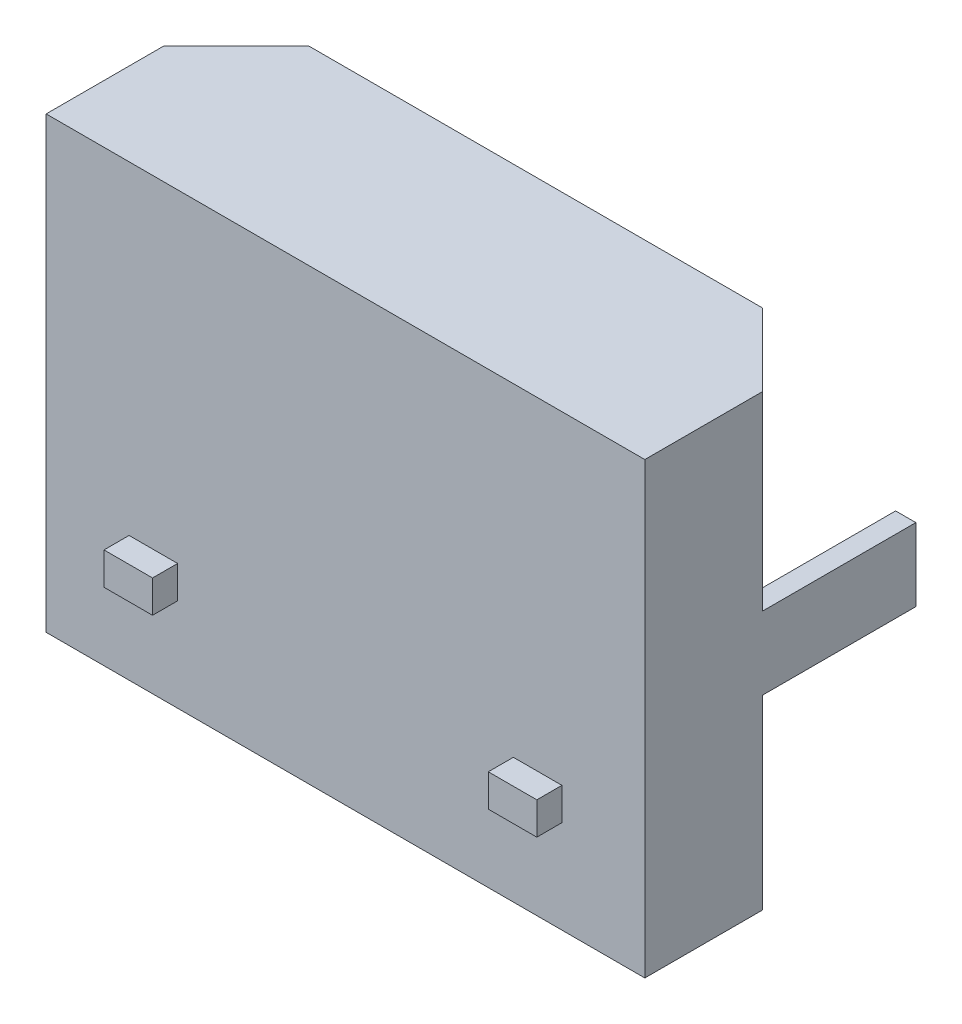
from build123d import *

# Parameters (mm, degrees)
BULK_DEPTH              = 2.75
BULK_DEPTH_BACK         = 2.8
PEG_BASE_SKETCH_W       = 0.25
PEG_BASE_SKETCH_H       = 0.9
PEGS_DEPTH              = 3.35
RECEPTACLE_DEPTH        = 6.201201784
RECEPTACLE_DEPTH_BACK   = 0.75
SKETCH3_W               = 0.6
SKETCH3_H               = 0.4
UPPER_FINS_DEPTH        = 0.31
ALTIUM_AXIS_ALIGN_ANGLE = 90


with BuildPart() as part:
    # Base sketch → Bulk (new, two sides: drawn at the far end of the back side and taken through both)
    with BuildSketch(Plane.XY.offset(-BULK_DEPTH_BACK)):
        Polygon((3.7, 2.35), (-3.7, 2.35), (-3.7, 0.896446609), (-2.803553391, 0), (2.803553391, 0), (3.7, 0.896446609), align=None)
    extrude(amount=BULK_DEPTH + BULK_DEPTH_BACK)

    # Peg base sketch → Pegs (add)
    with BuildSketch(Plane(origin=(0, 2.35, 0), x_dir=(1, 0, 0), z_dir=(0, 1, 0))):
        with Locations((3.575, 0)):
            Rectangle(PEG_BASE_SKETCH_W, PEG_BASE_SKETCH_H)
        with Locations((-3.575, 0)):
            Rectangle(PEG_BASE_SKETCH_W, PEG_BASE_SKETCH_H)
    extrude(amount=-PEGS_DEPTH)

    # Base sketch_3 → Receptacle (cut, two sides: drawn at the far end of the back side and taken through both)
    with BuildSketch(Plane.XY.offset(-RECEPTACLE_DEPTH_BACK)):
        Polygon((3.45, 2.1), (-3.45, 2.1), (-3.45, 1), (-2.7, 0.25), (2.7, 0.25), (3.45, 1), align=None)
    extrude(amount=RECEPTACLE_DEPTH + RECEPTACLE_DEPTH_BACK, mode=Mode.SUBTRACT)

    # Sketch3 → Upper fins (add)
    with BuildSketch(Plane(origin=(0, 2.35, 0), x_dir=(1, 0, 0), z_dir=(0, 1, 0))):
        with Locations((-2.375, -1.4)):
            Rectangle(SKETCH3_W, SKETCH3_H)
        with Locations((2.375, -1.4)):
            Rectangle(SKETCH3_W, SKETCH3_H)
    extrude(amount=UPPER_FINS_DEPTH)


with BuildPart() as part_1:
    # Altium axis align: moved
    add(part.part.rotate(Axis((0, 0, 0), (1, 0, 0)), ALTIUM_AXIS_ALIGN_ANGLE))


solid = part_1.part
